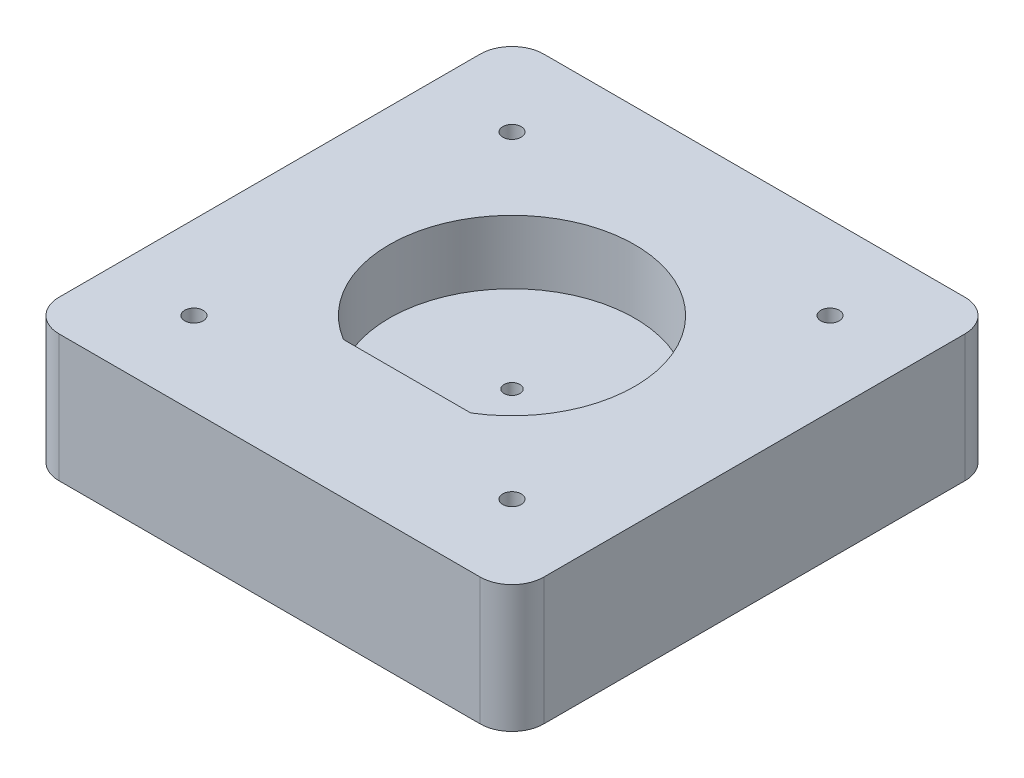
from build123d import *

# Parameters (mm, degrees)
SKETCH2_W                     = 76.2
SKETCH2_H                     = 76.2
BOSS_EXTRUDE1_DEPTH           = 20
CUT_EXTRUDE1_DEPTH            = 10
SKETCH4_R                     = 10
CUT_EXTRUDE2_DEPTH            = 5
TAP_DRILL_FOR_M3X0_5_TAP1_D   = 2.5
FILLET1_R                     = 5
TAP_DRILL_FOR_M3_5X0_6_TAP1_D = 2.9


with BuildPart() as part:
    # Sketch2 → Boss-Extrude1 (new body)
    with BuildSketch(Plane(origin=(0, 0, 0), x_dir=(1, 0, 0), z_dir=(0, 1, 0))):
        Rectangle(SKETCH2_W, SKETCH2_H)
    extrude(amount=BOSS_EXTRUDE1_DEPTH)

    # Sketch3 → Cut-Extrude1 (cut)
    with BuildSketch(Plane(origin=(0, 20, 0), x_dir=(1, 0, 0), z_dir=(0, 1, 0))):
        with BuildLine():
            Line((-10, -16.507271125), (10, -16.507271125))
            ThreePointArc((10, -16.507271125), (0, 19.3), (-10, -16.507271125))
        make_face()
    extrude(amount=-CUT_EXTRUDE1_DEPTH, mode=Mode.SUBTRACT)

    # Sketch4 → Cut-Extrude2 (cut)
    with BuildSketch(Plane.XZ):
        Circle(SKETCH4_R)
    extrude(amount=-CUT_EXTRUDE2_DEPTH, mode=Mode.SUBTRACT)

    # Tap Drill for M3x0.5 Tap1 (through all)
    with Locations(Plane(origin=(0, 5, 0), x_dir=(-1, 0, 0), z_dir=(0, -1, 0))):
        with Locations((0, 0)):
            Hole(TAP_DRILL_FOR_M3X0_5_TAP1_D / 2)

    # Fillet1
    fillet1_edges = [part.edges().sort_by_distance(p)[0] for p in [
        (38.1, 10, 38.1),
        (-38.1, 10, 38.1),
        (-38.1, 10, -38.1),
        (38.1, 10, -38.1),
    ]]
    fillet(fillet1_edges, radius=FILLET1_R)

    # Tap Drill for M3.5x0.6 Tap1 (through all)
    with Locations(Plane(origin=(0, 0, 0), x_dir=(-1, 0, 0), z_dir=(0, -1, 0))):
        with Locations((25, 25), (-25, -25), (-25, 25), (25, -25)):
            Hole(TAP_DRILL_FOR_M3_5X0_6_TAP1_D / 2)


solid = part.part
